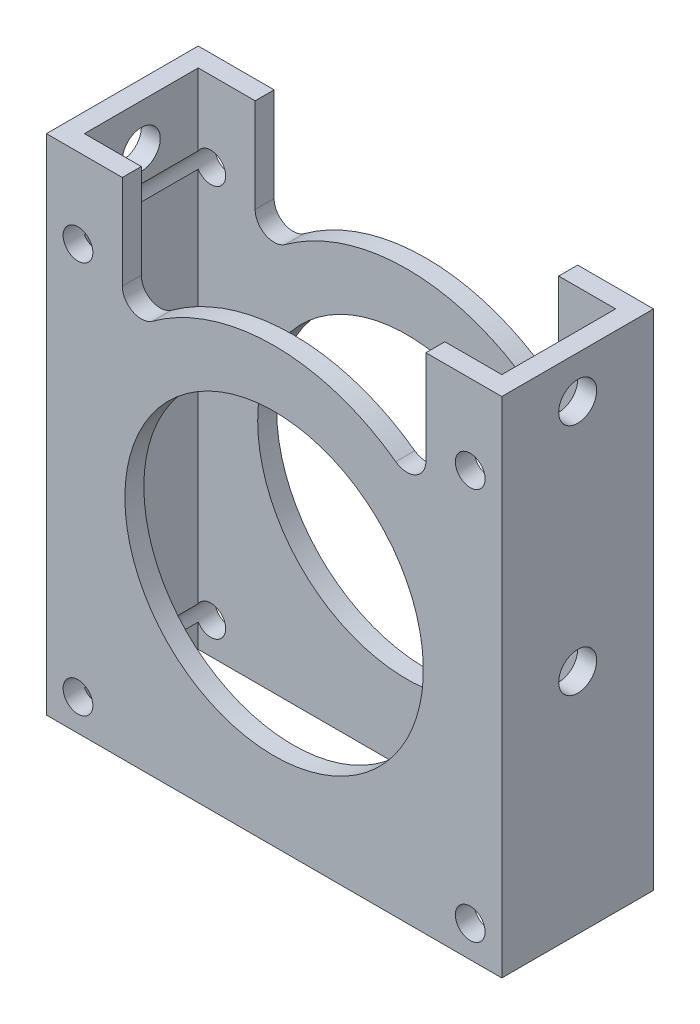
from build123d import *

# Parameters (mm, degrees)
SKETCH1_W           = 76.2
SKETCH1_H           = 25.4
SKETCH1_W_2         = 69.85
SKETCH1_H_2         = 19.05
EXTRUDE_THIN1_DEPTH = 49.276
SKETCH2_R           = 2.4892
SKETCH2_R_2         = 24.97201
CUT_EXTRUDE1_DEPTH  = 52.578
CUT_EXTRUDE2_DEPTH  = 26.4
SKETCH6_R           = 3.175
CUT_EXTRUDE3_DEPTH  = 77.2
SKETCH7_R           = 3.175
CUT_EXTRUDE4_DEPTH  = 77.2


with BuildPart() as part:
    # Sketch1 → Extrude-Thin1 (new body, symmetric)
    with BuildSketch(Plane(origin=(0, 0, 0), x_dir=(1, 0, 0), z_dir=(0, 1, 0))):
        with Locations((38.1, 12.7)):
            Rectangle(SKETCH1_W, SKETCH1_H)
        with Locations((38.1, 12.7)):
            Rectangle(SKETCH1_W_2, SKETCH1_H_2, mode=Mode.SUBTRACT)
    extrude(amount=EXTRUDE_THIN1_DEPTH, both=True)

    # Sketch2 → Cut-Extrude1 (cut)
    with BuildSketch(Plane(origin=(0, 0, -25.4), x_dir=(-1, 0, 0), z_dir=(0, 0, -1))):
        with Locations((-5.2832, 21.6408)):
            Circle(SKETCH2_R)
        with Locations((-38.1, -11.176)):
            Circle(SKETCH2_R_2)
        with Locations((-70.9168, -43.9928)):
            Circle(SKETCH2_R)
    cut_extrude1 = extrude(amount=-CUT_EXTRUDE1_DEPTH, mode=Mode.SUBTRACT)

    # Sketch5 → Cut-Extrude2 (cut, through all)
    with BuildSketch(Plane(origin=(0, 0, -25.4), x_dir=(-1, 0, 0), z_dir=(0, 0, -1))):
        Polygon((0, 49.276), (-76.2, 49.276), (-76.2, 34.9885), (-63.5, 34.9885), (-12.7, 34.9885), (0, 34.9885), align=None)
        with BuildLine():
            Line((-12.7, 34.9885), (-63.5, 34.9885))
            Line((-63.5, 34.9885), (-63.5, 19.241588866))
            ThreePointArc((-63.5, 19.241588866), (-61.762611537, 16.410705953), (-58.451875232, 16.677992057))
            ThreePointArc((-58.451875232, 16.677992057), (-38.1, 23.32101), (-17.748124768, 16.677992057))
            ThreePointArc((-17.748124768, 16.677992057), (-14.437388463, 16.410705953), (-12.7, 19.241588866))
            Line((-12.7, 19.241588866), (-12.7, 34.9885))
        make_face()
    extrude(amount=-CUT_EXTRUDE2_DEPTH, mode=Mode.SUBTRACT)

    # Sketch6 → Cut-Extrude3 (cut, through all)
    with BuildSketch(Plane.ZY):
        with Locations((-12.7, 27.94)):
            Circle(SKETCH6_R)
    extrude(amount=-CUT_EXTRUDE3_DEPTH, mode=Mode.SUBTRACT)

    # Mirror1: Cut-Extrude1 across plane
    add(cut_extrude1.mirror(Plane.ZY.offset(-38.1)), mode=Mode.SUBTRACT)

    # Sketch7 → Cut-Extrude4 (cut, through all)
    with BuildSketch(Plane.ZY):
        with Locations((-12.7, -11.176)):
            Circle(SKETCH7_R)
    extrude(amount=-CUT_EXTRUDE4_DEPTH, mode=Mode.SUBTRACT)


solid = part.part
